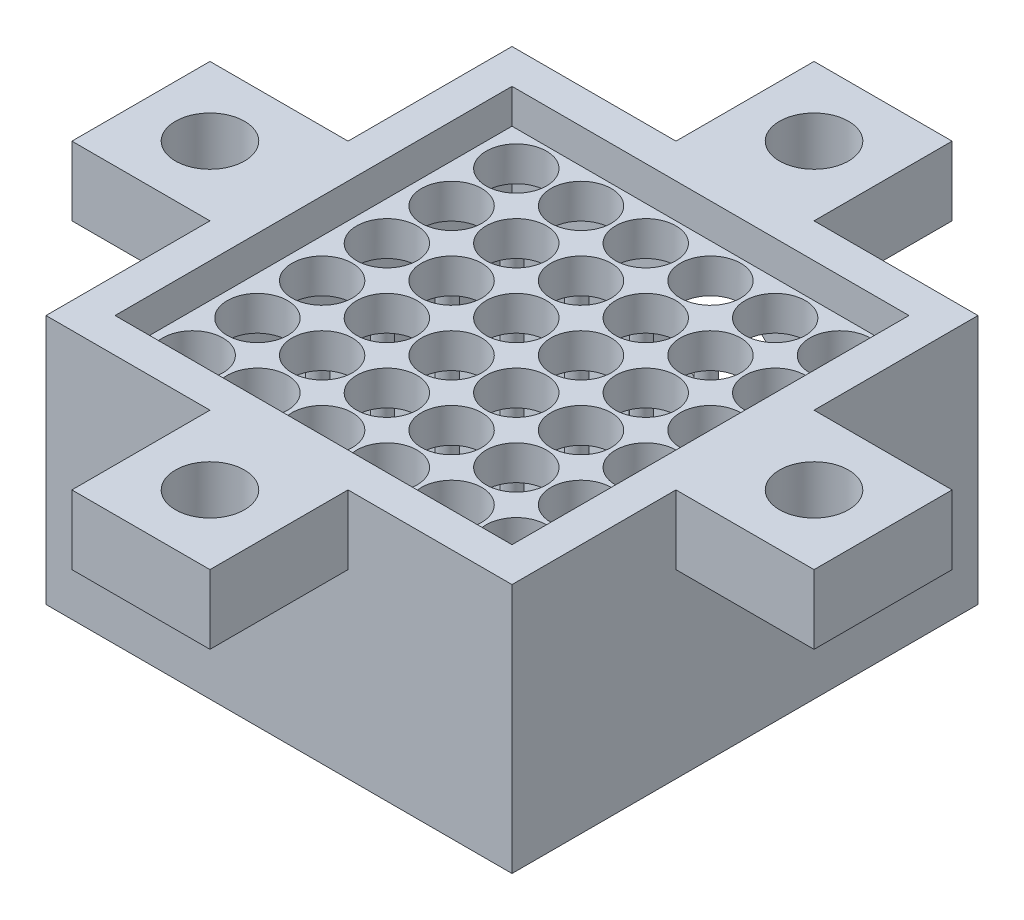
from build123d import *

# Parameters (mm, degrees)
SKETCH1_W            = 27
SKETCH1_H            = 27
SKETCH1_W_2          = 23
SKETCH1_H_2          = 23
BOSS_EXTRUDE1_DEPTH  = 2
SKETCH2_W            = 27
SKETCH2_H            = 27
BOSS_EXTRUDE2_DEPTH  = 2
SKETCH12_W           = 8
SKETCH12_H           = 4
BOSS_EXTRUDE9_DEPTH  = 8
CIRPATTERN1_COUNT    = 4
SKETCH20_R           = 2
CUT_EXTRUDE11_DEPTH  = 4
CIRPATTERN2_COUNT    = 4
SKETCH13_R           = 1.75
CUT_EXTRUDE4_DEPTH   = 2
LPATTERN3_COUNT      = 6
LPATTERN3_PITCH      = 3.75
LPATTERN3_COUNT_DIR2 = 6
LPATTERN3_PITCH_DIR2 = 3.75
SKETCH14_W           = 27
SKETCH14_H           = 27
SKETCH14_W_2         = 23
SKETCH14_H_2         = 23
BOSS_EXTRUDE10_DEPTH = 8.5
BOSS_EXTRUDE11_DEPTH = 23
SKETCH18_W           = 27
SKETCH18_H           = 27
BOSS_EXTRUDE12_DEPTH = 2
SKETCH17_R           = 4.25
CUT_EXTRUDE10_DEPTH  = 2
SKETCH19_R           = 0.5
BOSS_EXTRUDE13_DEPTH = 6.51087


with BuildPart() as part:
    # Sketch1 → Boss-Extrude1 (new body)
    with BuildSketch(Plane(origin=(0, 0, 0), x_dir=(1, 0, 0), z_dir=(0, 1, 0))):
        Rectangle(SKETCH1_W, SKETCH1_H)
        Rectangle(SKETCH1_W_2, SKETCH1_H_2, mode=Mode.SUBTRACT)
    extrude(amount=BOSS_EXTRUDE1_DEPTH)

    # Sketch2 → Boss-Extrude2 (add)
    with BuildSketch(Plane.XZ):
        Rectangle(SKETCH2_W, SKETCH2_H)
    extrude(amount=BOSS_EXTRUDE2_DEPTH)

    # Sketch12 → Boss-Extrude9 (add)
    with BuildSketch(Plane.ZY.offset(13.5)):
        Rectangle(SKETCH12_W, SKETCH12_H)
    boss_extrude9 = extrude(amount=BOSS_EXTRUDE9_DEPTH)

    # CirPattern1: Boss-Extrude9 ×4 about axis
    cirpattern1_axis = Axis((0, 0, 0), (0, 1, 0))
    for i in range(1, CIRPATTERN1_COUNT):
        add(boss_extrude9.rotate(cirpattern1_axis, i * 360 / CIRPATTERN1_COUNT))

    # Sketch20 → Cut-Extrude11 (cut)
    with BuildSketch(Plane(origin=(0, 2, 0), x_dir=(1, 0, 0), z_dir=(0, 1, 0))):
        with Locations((0, -17.5)):
            Circle(SKETCH20_R)
    cut_extrude11 = extrude(amount=-CUT_EXTRUDE11_DEPTH, mode=Mode.SUBTRACT)

    # CirPattern2: Cut-Extrude11 ×4 about axis
    cirpattern2_axis = Axis((0, 0, 0), (0, 1, 0))
    for i in range(1, CIRPATTERN2_COUNT):
        add(cut_extrude11.rotate(cirpattern2_axis, i * 360 / CIRPATTERN2_COUNT), mode=Mode.SUBTRACT)

    # Sketch13 → Cut-Extrude4 (cut)
    with BuildSketch(Plane(origin=(0, 0, 0), x_dir=(1, 0, 0), z_dir=(0, 1, 0))):
        with Locations((9.5, 9.5)):
            Circle(SKETCH13_R)
    cut_extrude4 = extrude(amount=-CUT_EXTRUDE4_DEPTH, mode=Mode.SUBTRACT)

    # LPattern3: Cut-Extrude4 6 × 6
    with Locations(*[(-j * LPATTERN3_PITCH_DIR2, 0, i * LPATTERN3_PITCH) for i in range(LPATTERN3_COUNT) for j in range(LPATTERN3_COUNT_DIR2) if (i, j) != (0, 0)]):
        add(cut_extrude4, mode=Mode.SUBTRACT)

    # Sketch14 → Boss-Extrude10 (add)
    with BuildSketch(Plane.XZ.offset(2)):
        Rectangle(SKETCH14_W, SKETCH14_H)
        Rectangle(SKETCH14_W_2, SKETCH14_H_2, mode=Mode.SUBTRACT)
    extrude(amount=BOSS_EXTRUDE10_DEPTH)

    # Sketch16 → Boss-Extrude11 (add)
    with BuildSketch(Plane.ZY.offset(-11.5)):
        Polygon((11.5, -10.5), (-11.5, -10.5), (-11.5, -9.5), (11.5, -3), align=None)
    extrude(amount=BOSS_EXTRUDE11_DEPTH)

    # Sketch18 → Boss-Extrude12 (add)
    with BuildSketch(Plane.XZ.offset(10.5)):
        Rectangle(SKETCH18_W, SKETCH18_H)
    extrude(amount=BOSS_EXTRUDE12_DEPTH)

    # Sketch17 → Cut-Extrude10 (cut)
    with BuildSketch(Plane(origin=(0, 0, -13.5), x_dir=(-1, 0, 0), z_dir=(0, 0, -1))):
        with Locations((0, -6.25)):
            Circle(SKETCH17_R)
    extrude(amount=-CUT_EXTRUDE10_DEPTH, mode=Mode.SUBTRACT)

    # Sketch19 → Boss-Extrude13 (add)
    with BuildSketch(Plane.XZ.offset(2)):
        Circle(SKETCH19_R)
        with Locations((3.75, 0)):
            Circle(SKETCH19_R)
        with Locations((0, 3.75)):
            Circle(SKETCH19_R)
        with Locations((-3.75, 3.75)):
            Circle(SKETCH19_R)
        with Locations((3.75, 3.75)):
            Circle(SKETCH19_R)
        with Locations((7.5, 3.75)):
            Circle(SKETCH19_R)
        with Locations((7.5, 7.5)):
            Circle(SKETCH19_R)
        with Locations((3.75, 7.5)):
            Circle(SKETCH19_R)
        with Locations((0, 7.5)):
            Circle(SKETCH19_R)
        with Locations((-3.75, 7.5)):
            Circle(SKETCH19_R)
        with Locations((-7.5, 7.5)):
            Circle(SKETCH19_R)
        with Locations((-7.5, 3.75)):
            Circle(SKETCH19_R)
        with Locations((-7.5, 0)):
            Circle(SKETCH19_R)
        with Locations((-3.75, 0)):
            Circle(SKETCH19_R)
        with Locations((-3.75, -3.75)):
            Circle(SKETCH19_R)
        with Locations((-7.5, -3.75)):
            Circle(SKETCH19_R)
        with Locations((-7.5, -7.5)):
            Circle(SKETCH19_R)
        with Locations((-3.75, -7.5)):
            Circle(SKETCH19_R)
        with Locations((0, -7.5)):
            Circle(SKETCH19_R)
        with Locations((0, -3.75)):
            Circle(SKETCH19_R)
        with Locations((3.75, -3.75)):
            Circle(SKETCH19_R)
        with Locations((3.75, -7.5)):
            Circle(SKETCH19_R)
        with Locations((7.5, -7.5)):
            Circle(SKETCH19_R)
        with Locations((7.5, -3.75)):
            Circle(SKETCH19_R)
        with Locations((7.5, 0)):
            Circle(SKETCH19_R)
    extrude(amount=BOSS_EXTRUDE13_DEPTH)


solid = part.part
